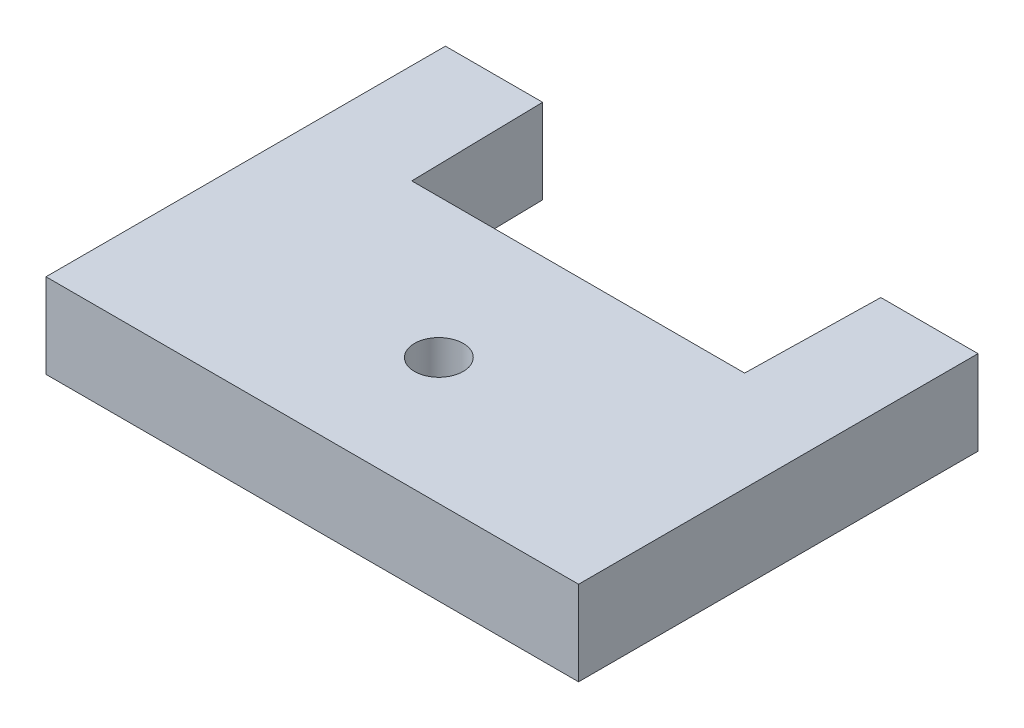
from build123d import *

# Parameters (mm, degrees)
SKETCH1_W             = 40
SKETCH1_H             = 30
BOSS_EXTRUDE1_DEPTH   = 6.35
CUT_EXTRUDE1_DEPTH    = 7.35
F_6_CLEARANCE_HOLE1_D = 3.6576


with BuildPart() as part:
    # Sketch1 → Boss-Extrude1 (new body)
    with BuildSketch(Plane(origin=(0, 0, 0), x_dir=(1, 0, 0), z_dir=(0, 1, 0))):
        Rectangle(SKETCH1_W, SKETCH1_H)
    extrude(amount=BOSS_EXTRUDE1_DEPTH)

    # Sketch2 → Cut-Extrude1 (cut, through all)
    with BuildSketch(Plane(origin=(0, 6.35, 0), x_dir=(1, 0, 0), z_dir=(0, 1, 0))):
        Polygon((-12.7, 15), (-12.5, 4.97), (12.5, 4.97), (12.7, 15), align=None)
    extrude(amount=-CUT_EXTRUDE1_DEPTH, mode=Mode.SUBTRACT)

    # #6 Clearance Hole1 (through all)
    with Locations(Plane(origin=(0, 6.35, 5.4948), x_dir=(0, 0, 1), z_dir=(0, 1, 0))):
        with Locations((0, 0)):
            Hole(F_6_CLEARANCE_HOLE1_D / 2)


solid = part.part
